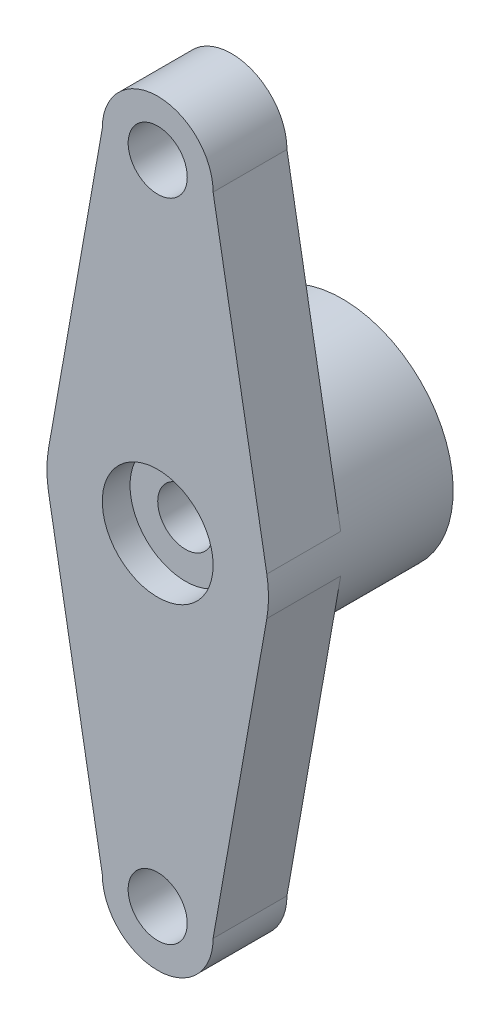
from build123d import *

# Parameters (mm, degrees)
BOSS_EXTRUDE1_DEPTH = 4
SKETCH5_R           = 6
BOSS_EXTRUDE3_DEPTH = 6
SKETCH6_R           = 3
CUT_EXTRUDE1_DEPTH  = 5
SKETCH7_R           = 1.5
CUT_EXTRUDE2_DEPTH  = 6
SKETCH4_R           = 1.6
CUT_EXTRUDE3_DEPTH  = 11
SKETCH8_R           = 3
CUT_EXTRUDE4_DEPTH  = 1.5


with BuildPart() as part:
    # Sketch1 → Boss-Extrude1 (new body)
    with BuildSketch(Plane.XY):
        with BuildLine():
            Line((3, 17.5), (5.908426238, 1.044269788))
            ThreePointArc((5.908426238, 1.044269788), (6, 0), (5.908426238, -1.044269788))
            Line((5.908426238, -1.044269788), (3, -17.5))
            ThreePointArc((3, -17.5), (0, -20.5), (-3, -17.5))
            Line((-3, -17.5), (-5.908426238, -1.044269788))
            ThreePointArc((-5.908426238, -1.044269788), (-6, 0), (-5.908426238, 1.044269788))
            Line((-5.908426238, 1.044269788), (-3, 17.5))
            ThreePointArc((-3, 17.5), (0, 20.5), (3, 17.5))
        make_face()
    extrude(amount=-BOSS_EXTRUDE1_DEPTH)

    # Sketch5 → Boss-Extrude3 (add)
    with BuildSketch(Plane(origin=(0, 0, -4), x_dir=(-1, 0, 0), z_dir=(0, 0, -1))):
        Circle(SKETCH5_R)
    extrude(amount=BOSS_EXTRUDE3_DEPTH)

    # Sketch6 → Cut-Extrude1 (cut)
    with BuildSketch(Plane(origin=(0, 0, -10), x_dir=(-1, 0, 0), z_dir=(0, 0, -1))):
        Circle(SKETCH6_R)
    extrude(amount=-CUT_EXTRUDE1_DEPTH, mode=Mode.SUBTRACT)

    # Sketch7 → Cut-Extrude2 (cut, through all)
    with BuildSketch(Plane(origin=(0, 0, -5), x_dir=(-1, 0, 0), z_dir=(0, 0, -1))):
        Circle(SKETCH7_R)
    extrude(amount=-CUT_EXTRUDE2_DEPTH, mode=Mode.SUBTRACT)

    # Sketch4 → Cut-Extrude3 (cut, through all)
    with BuildSketch(Plane.XY):
        with Locations((0, 17.5)):
            Circle(SKETCH4_R)
        with Locations((0, -17.5)):
            Circle(SKETCH4_R)
    extrude(amount=-CUT_EXTRUDE3_DEPTH, mode=Mode.SUBTRACT)

    # Sketch8 → Cut-Extrude4 (cut)
    with BuildSketch(Plane.XY):
        Circle(SKETCH8_R)
    extrude(amount=-CUT_EXTRUDE4_DEPTH, mode=Mode.SUBTRACT)


solid = part.part
